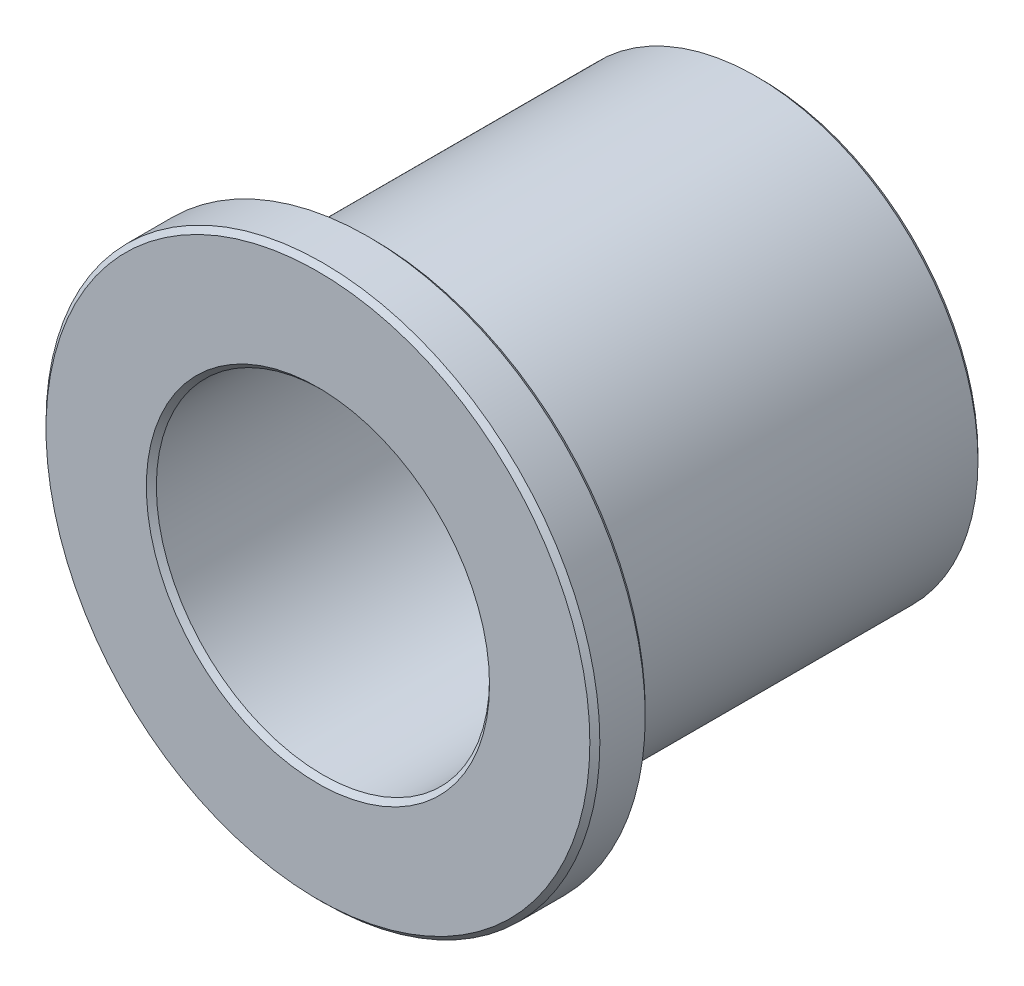
from build123d import *

# Parameters (mm, degrees)
BOSS_EXTRUDE1_START = 6.35
SKETCH3_R           = 7.9375
SKETCH3_R_2         = 4.7752
BOSS_EXTRUDE1_DEPTH = 1.5875
BOSS_EXTRUDE2_START = 4.7625
SKETCH4_R           = 6.3627
SKETCH4_R_2         = 4.7752
BOSS_EXTRUDE2_DEPTH = 11.1125
CHAMFER1_SIZE       = 0.143256


with BuildPart() as part:
    # Sketch3 → Boss-Extrude1 (new body)
    with BuildSketch(Plane.XY.offset(BOSS_EXTRUDE1_START)):
        Circle(SKETCH3_R)
        Circle(SKETCH3_R_2, mode=Mode.SUBTRACT)
    extrude(amount=-BOSS_EXTRUDE1_DEPTH)

    # Sketch4 → Boss-Extrude2 (add)
    with BuildSketch(Plane.XY.offset(BOSS_EXTRUDE2_START)):
        Circle(SKETCH4_R)
        Circle(SKETCH4_R_2, mode=Mode.SUBTRACT)
    extrude(amount=-BOSS_EXTRUDE2_DEPTH)

    # Chamfer1
    chamfer1_edges = [part.edges().sort_by_distance(p)[0] for p in [
        (-4.7752, 0, -6.35),
        (-6.3627, 0, 4.7625),
        (-7.9375, 0, 6.35),
        (-7.9375, 0, 4.7625),
        (-4.7752, 0, 6.35),
        (-6.3627, 0, -6.35),
    ]]
    chamfer(chamfer1_edges, length=CHAMFER1_SIZE)


solid = part.part
